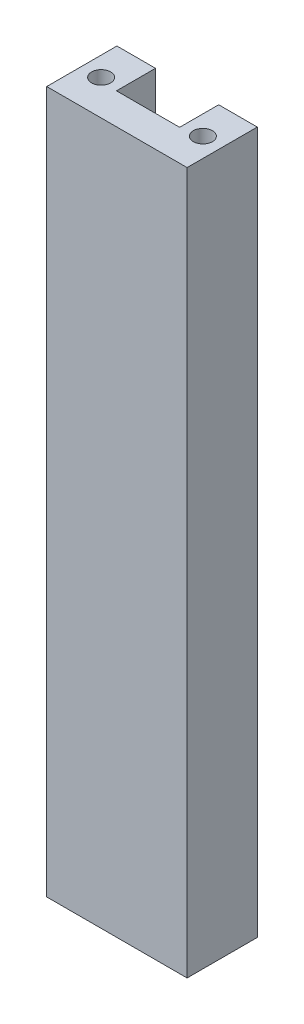
from build123d import *

# Parameters (mm, degrees)
BOSS_EXTRUDE1_DEPTH           = 127
TAP_DRILL_FOR_8_32_TAP2_D     = 3.4544
TAP_DRILL_FOR_8_32_TAP2_DEPTH = 13.97
TAP_DRILL_FOR_8_32_TAP2_TIP   = 1.037806461
TAP_DRILL_FOR_8_32_TAP3_D     = 3.4544
TAP_DRILL_FOR_8_32_TAP3_DEPTH = 13.97
TAP_DRILL_FOR_8_32_TAP3_TIP   = 1.037806461


with BuildPart() as part:
    # Sketch1 → Boss-Extrude1 (new body)
    with BuildSketch(Plane(origin=(0, 0, 0), x_dir=(1, 0, 0), z_dir=(0, 1, 0))):
        Polygon((18.415, 0), (25.4, 0), (25.4, -12.7), (0, -12.7), (0, 0), (6.985, 0), (6.985, -7.065187713), (18.415, -7.065187713), align=None)
    extrude(amount=BOSS_EXTRUDE1_DEPTH)

    # Tap Drill for #8-32 Tap2
    with Locations(Plane(origin=(3.4925, 0, 6.35), x_dir=(0, 0, -1), z_dir=(0, -1, 0))):
        with Locations((0, 0), (0, 18.415)):
            Hole(TAP_DRILL_FOR_8_32_TAP2_D / 2, depth=TAP_DRILL_FOR_8_32_TAP2_DEPTH)
            with Locations((0, 0, -(TAP_DRILL_FOR_8_32_TAP2_DEPTH + TAP_DRILL_FOR_8_32_TAP2_TIP / 2))):  # 118° drill point
                Cone(0, TAP_DRILL_FOR_8_32_TAP2_D / 2, TAP_DRILL_FOR_8_32_TAP2_TIP, mode=Mode.SUBTRACT)

    # Tap Drill for #8-32 Tap3
    with Locations(Plane(origin=(3.4925, 127, 6.35), x_dir=(0, 0, 1), z_dir=(0, 1, 0))):
        with Locations((0, 0), (0, 18.415)):
            Hole(TAP_DRILL_FOR_8_32_TAP3_D / 2, depth=TAP_DRILL_FOR_8_32_TAP3_DEPTH)
            with Locations((0, 0, -(TAP_DRILL_FOR_8_32_TAP3_DEPTH + TAP_DRILL_FOR_8_32_TAP3_TIP / 2))):  # 118° drill point
                Cone(0, TAP_DRILL_FOR_8_32_TAP3_D / 2, TAP_DRILL_FOR_8_32_TAP3_TIP, mode=Mode.SUBTRACT)


solid = part.part
